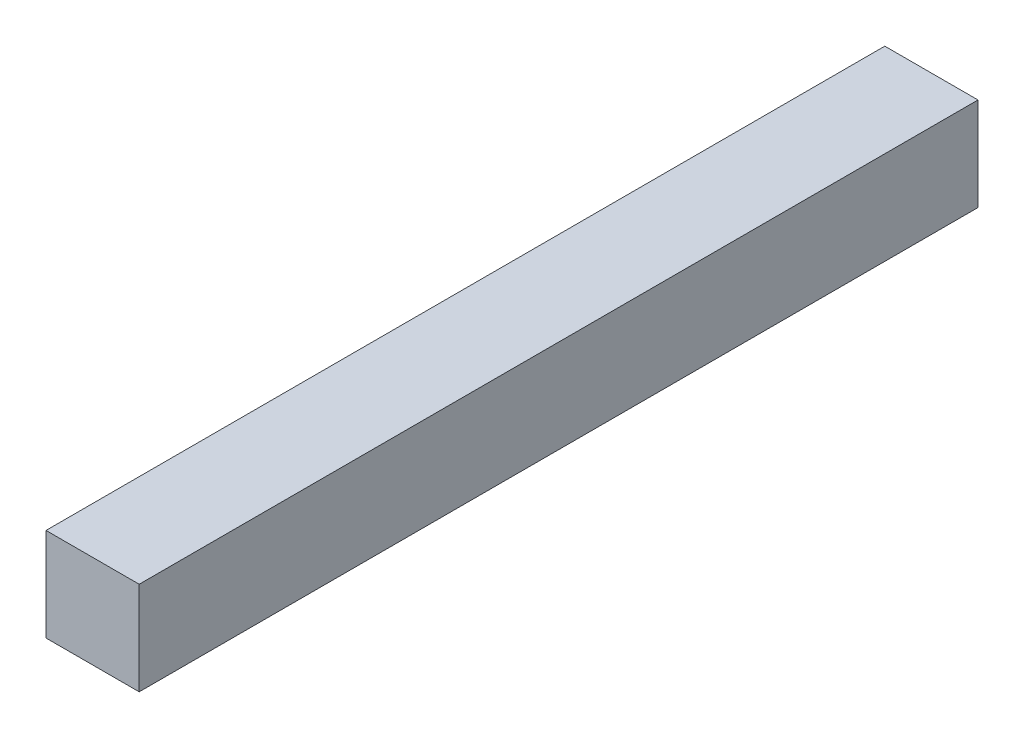
from build123d import *

# Parameters (mm, degrees)
SKETCH1_W           = 20
SKETCH1_H           = 20
BOSS_EXTRUDE1_DEPTH = 180


with BuildPart() as part:
    # Sketch1 → Boss-Extrude1 (new body)
    with BuildSketch(Plane.XY):
        Rectangle(SKETCH1_W, SKETCH1_H)
    extrude(amount=BOSS_EXTRUDE1_DEPTH)


solid = part.part
